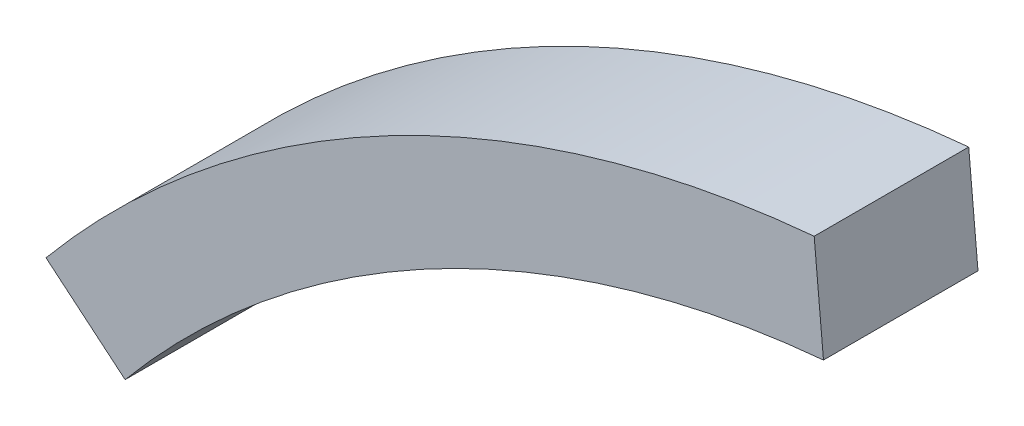
from build123d import *

# Parameters (mm, degrees)
BOSS_EXTRUDE1_DEPTH = 3


with BuildPart() as part:
    # Sketch1 → Boss-Extrude1 (new body)
    with BuildSketch(Plane.XY):
        with BuildLine():
            Line((-15.358457621, 12.810846167), (-16.894303383, 14.091930784))
            ThreePointArc((-16.894303383, 14.091930784), (-10.21555267, 19.484416431), (-1.981576668, 21.910576303))
            Line((-1.981576668, 21.910576303), (-1.801433335, 19.91870573))
            ThreePointArc((-1.801433335, 19.91870573), (-9.286866064, 17.713105846), (-15.358457621, 12.810846167))
        make_face()
    extrude(amount=BOSS_EXTRUDE1_DEPTH)


solid = part.part
